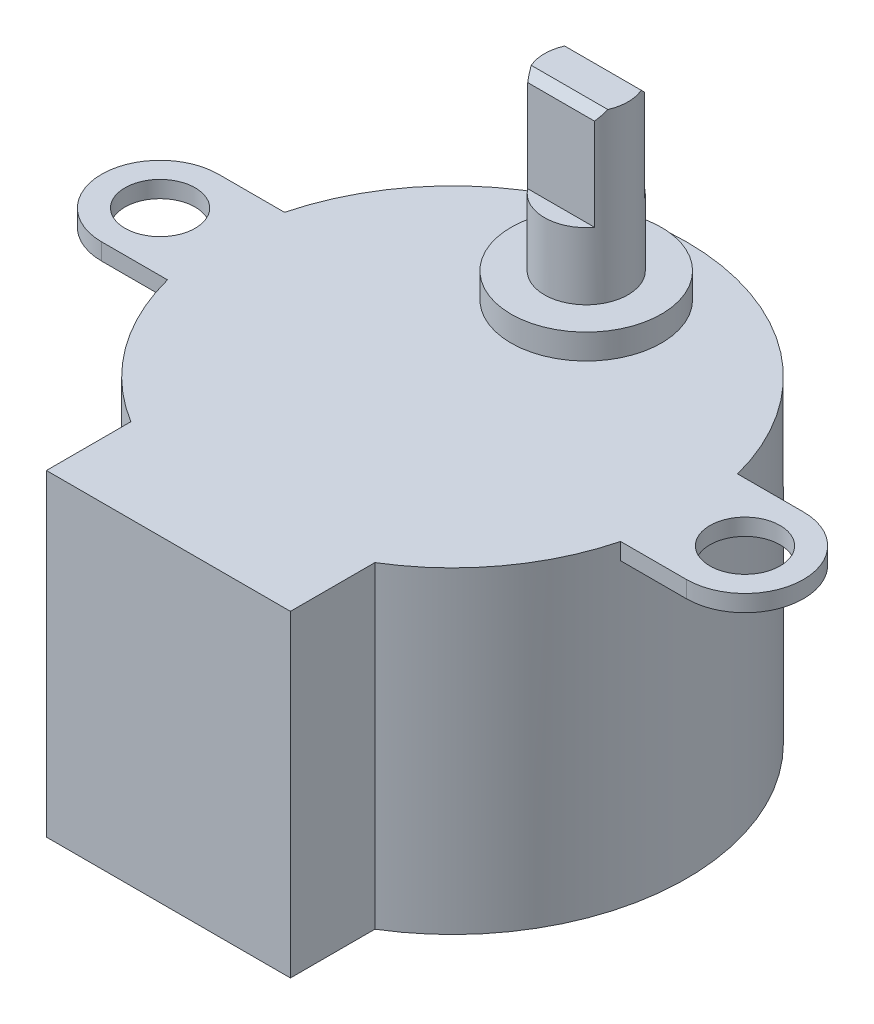
from build123d import *

# Parameters (mm, degrees)
SKETCH1_R           = 14
BOSS_EXTRUDE1_DEPTH = 19
SKETCH2_R           = 2.1
BOSS_EXTRUDE2_DEPTH = 1
SKETCH3_R           = 4.5
BOSS_EXTRUDE3_DEPTH = 1.5
SKETCH4_R           = 2.5
BOSS_EXTRUDE4_DEPTH = 10
CUT_EXTRUDE1_DEPTH  = 6
CHAMFER1_SIZE       = 0.5
BOSS_EXTRUDE5_DEPTH = 19


with BuildPart() as part:
    # Sketch1 → Boss-Extrude1 (new body)
    with BuildSketch(Plane(origin=(0, 0, 0), x_dir=(1, 0, 0), z_dir=(0, 1, 0))):
        Circle(SKETCH1_R)
    extrude(amount=BOSS_EXTRUDE1_DEPTH)

    # Sketch2 → Boss-Extrude2 (add)
    with BuildSketch(Plane(origin=(0, 19, 0), x_dir=(1, 0, 0), z_dir=(0, 1, 0))):
        with BuildLine():
            Line((-17.5, 3.5), (-13.555441712, 3.5))
            ThreePointArc((-13.555441712, 3.5), (-14, 0), (-13.555441712, -3.5))
            Line((-13.555441712, -3.5), (-17.5, -3.5))
            ThreePointArc((-17.5, -3.5), (-21, 0), (-17.5, 3.5))
        make_face()
        with Locations((-17.5, 0)):
            Circle(SKETCH2_R, mode=Mode.SUBTRACT)
        with BuildLine():
            Line((17.5, -3.5), (13.555441712, -3.5))
            ThreePointArc((13.555441712, -3.5), (14, 0), (13.555441712, 3.5))
            Line((13.555441712, 3.5), (17.5, 3.5))
            ThreePointArc((17.5, 3.5), (21, 0), (17.5, -3.5))
        make_face()
        with Locations((17.5, 0)):
            Circle(SKETCH2_R, mode=Mode.SUBTRACT)
    extrude(amount=-BOSS_EXTRUDE2_DEPTH)

    # Sketch3 → Boss-Extrude3 (add)
    with BuildSketch(Plane(origin=(0, 19, 0), x_dir=(1, 0, 0), z_dir=(0, 1, 0))):
        with Locations((0, 8)):
            Circle(SKETCH3_R)
    extrude(amount=BOSS_EXTRUDE3_DEPTH)

    # Sketch4 → Boss-Extrude4 (add)
    with BuildSketch(Plane(origin=(0, 20.5, 0), x_dir=(1, 0, 0), z_dir=(0, 1, 0))):
        with Locations((0, 8)):
            Circle(SKETCH4_R)
    extrude(amount=BOSS_EXTRUDE4_DEPTH)

    # Sketch5 → Cut-Extrude1 (cut)
    with BuildSketch(Plane(origin=(0, 30.5, 0), x_dir=(1, 0, 0), z_dir=(0, 1, 0))):
        with BuildLine():
            Line((-2, 9.5), (2, 9.5))
            ThreePointArc((2, 9.5), (0, 10.5), (-2, 9.5))
        make_face()
        with BuildLine():
            Line((-2, 6.5), (2, 6.5))
            ThreePointArc((2, 6.5), (0, 5.5), (-2, 6.5))
        make_face()
    extrude(amount=-CUT_EXTRUDE1_DEPTH, mode=Mode.SUBTRACT)

    # Chamfer1
    chamfer1_edges = [part.edges().sort_by_distance(p)[0] for p in [
        (0, 30.5, -9.5),
        (0, 30.5, -6.5),
    ]]
    chamfer(chamfer1_edges, length=CHAMFER1_SIZE)

    # Sketch6 → Boss-Extrude5 (add)
    with BuildSketch(Plane(origin=(0, 19, 0), x_dir=(1, 0, 0), z_dir=(0, 1, 0))):
        with BuildLine():
            Line((-7.3, -17), (7.3, -17))
            Line((7.3, -17), (7.3, -11.94612908))
            ThreePointArc((7.3, -11.94612908), (0, -14), (-7.3, -11.94612908))
            Line((-7.3, -11.94612908), (-7.3, -17))
        make_face()
    extrude(amount=-BOSS_EXTRUDE5_DEPTH)


solid = part.part
